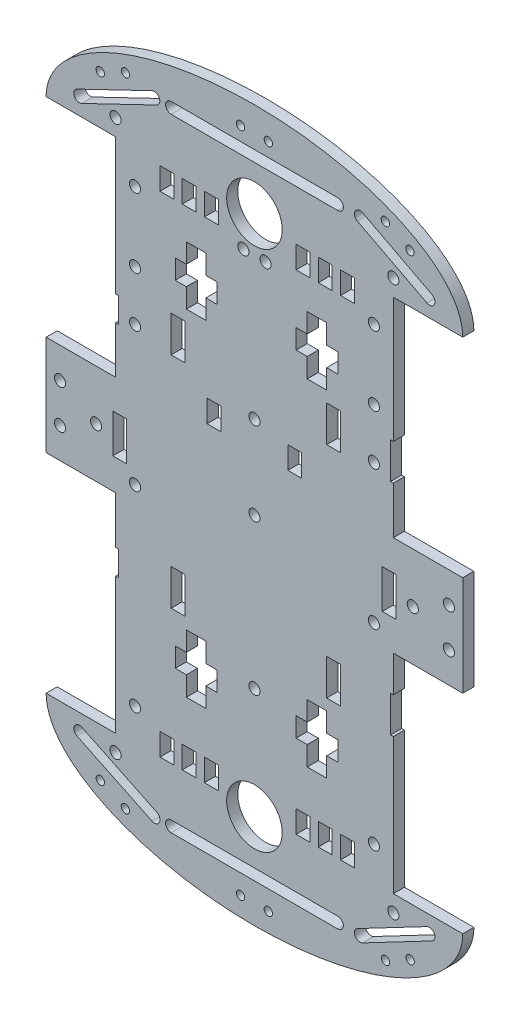
from build123d import *

# Parameters (mm, degrees)
SKETCH1_R           = 10
SKETCH1_R_2         = 1.972602619
BOSS_EXTRUDE2_DEPTH = 4
SKETCH3_R           = 2
CUT_EXTRUDE1_DEPTH  = 5.0000001
SKETCH4_R           = 2
CUT_EXTRUDE2_DEPTH  = 5.0000001
SKETCH5_W           = 5
SKETCH5_H           = 14
CUT_EXTRUDE3_DEPTH  = 5.0000001
SKETCH6_W           = 5
SKETCH6_H           = 14
CUT_EXTRUDE4_DEPTH  = 5.0000001
SKETCH7_W           = 5
SKETCH7_H           = 7.981312777
CUT_EXTRUDE6_DEPTH  = 5.0000001
SKETCH8_W           = 5
SKETCH8_H           = 8
CUT_EXTRUDE7_DEPTH  = 5.0000001
SKETCH9_W           = 5
SKETCH9_H           = 8
CUT_EXTRUDE8_DEPTH  = 5.0000001
SKETCH10_W          = 5
SKETCH10_H          = 8
CUT_EXTRUDE9_DEPTH  = 5.0000001
SKETCH11_W          = 5
SKETCH11_H          = 8
CUT_EXTRUDE10_DEPTH = 5.0000001
SKETCH12_W          = 5
SKETCH12_H          = 8
CUT_EXTRUDE12_DEPTH = 5.0000001
SKETCH13_W          = 5
SKETCH13_H          = 8
CUT_EXTRUDE13_DEPTH = 5.0000001
SKETCH14_W          = 5
SKETCH14_H          = 8
CUT_EXTRUDE14_DEPTH = 5.0000001
SKETCH15_W          = 5
SKETCH15_H          = 8
CUT_EXTRUDE15_DEPTH = 5.0000001
SKETCH16_W          = 5
SKETCH16_H          = 8
CUT_EXTRUDE16_DEPTH = 4
SKETCH17_W          = 5
SKETCH17_H          = 8
CUT_EXTRUDE17_DEPTH = 5.0000001
SKETCH18_W          = 5
SKETCH18_H          = 8
CUT_EXTRUDE18_DEPTH = 5.0000001
SKETCH19_R          = 2
CUT_EXTRUDE19_DEPTH = 5.0000001
SKETCH20_R          = 2
CUT_EXTRUDE20_DEPTH = 5.0000001
SKETCH21_R          = 2
CUT_EXTRUDE21_DEPTH = 5.0000001
SKETCH22_R          = 2
CUT_EXTRUDE22_DEPTH = 5.0000001
SKETCH23_R          = 2
CUT_EXTRUDE23_DEPTH = 5.0000001
SKETCH24_R          = 2
CUT_EXTRUDE24_DEPTH = 5.0000001
SKETCH25_W          = 5
SKETCH25_H          = 13
CUT_EXTRUDE25_DEPTH = 5.0000001
CUT_EXTRUDE26_DEPTH = 5.0000001
SKETCH27_W          = 5
SKETCH27_H          = 8
CUT_EXTRUDE27_DEPTH = 5.0000001
CUT_EXTRUDE29_DEPTH = 5.0000001
SKETCH29_R          = 1.5
CUT_EXTRUDE30_DEPTH = 5.0000001


with BuildPart() as part:
    # Sketch1 → Boss-Extrude2 (new body)
    with BuildSketch(Plane.XY):
        with BuildLine():
            Line((-50, 93), (-50, 44))
            Line((-50, 44), (-49, 44))
            Line((-49, 44), (-49, 35))
            Line((-49, 35), (-50, 35))
            Line((-50, 35), (-50, 18))
            Line((-50, 18), (-75, 18))
            Line((-75, 18), (-75, -18))
            Line((-75, -18), (-50, -18))
            Line((-50, -18), (-50, -35))
            Line((-50, -35), (-49, -35))
            Line((-49, -35), (-49, -44))
            Line((-49, -44), (-50, -44))
            Line((-50, -44), (-50, -93))
            Line((-50, -93), (-75, -93))
            add(Edge.make_bspline(
                [(-75, -93), (-75, -128), (0, -128), (75, -128), (75, -93)],
                knots=[3.141592654, 3.141592654, 3.141592654, 4.71238898, 4.71238898, 6.283185307, 6.283185307, 6.283185307], degree=2, weights=[1, 0.707106781, 1, 0.707106781, 1]))
            Line((75, -93), (50, -93))
            Line((50, -93), (50, -44))
            Line((50, -44), (49, -44))
            Line((49, -44), (49, -31))
            Line((49, -31), (50, -31))
            Line((50, -31), (50, -18))
            Line((50, -18), (75, -18))
            Line((75, -18), (75, 18))
            Line((75, 18), (50, 18))
            Line((50, 18), (50, 35))
            Line((50, 35), (49, 35))
            Line((49, 35), (49, 48))
            Line((49, 48), (50, 48))
            Line((50, 48), (50, 93))
            Line((50, 93), (75, 93))
            add(Edge.make_bspline(
                [(75, 93), (75, 128), (0, 128), (-75, 128), (-75, 93)],
                knots=[3.141592654, 3.141592654, 3.141592654, 4.71238898, 4.71238898, 6.283185307, 6.283185307, 6.283185307], degree=2, weights=[1, 0.707106781, 1, 0.707106781, 1]))
            Line((-75, 93), (-50, 93))
        make_face()
        with Locations((0, 94)):
            Circle(SKETCH1_R, mode=Mode.SUBTRACT)
        with Locations((0, -94)):
            Circle(SKETCH1_R, mode=Mode.SUBTRACT)
        Circle(SKETCH1_R_2, mode=Mode.SUBTRACT)
    extrude(amount=BOSS_EXTRUDE2_DEPTH)

    # Sketch3 → Cut-Extrude1 (cut, through all)
    with BuildSketch(Plane.XY.offset(4)):
        with Locations((0, 30)):
            Circle(SKETCH3_R)
    extrude(amount=-CUT_EXTRUDE1_DEPTH, mode=Mode.SUBTRACT)

    # Sketch4 → Cut-Extrude2 (cut, through all)
    with BuildSketch(Plane.XY.offset(4)):
        with Locations((0, -54)):
            Circle(SKETCH4_R)
    extrude(amount=-CUT_EXTRUDE2_DEPTH, mode=Mode.SUBTRACT)

    # Sketch5 → Cut-Extrude3 (cut, through all)
    with BuildSketch(Plane(origin=(0, 0, 0), x_dir=(-1, 0, 0), z_dir=(0, 0, -1))):
        with Locations((48.5, 0)):
            Rectangle(SKETCH5_W, SKETCH5_H)
    extrude(amount=-CUT_EXTRUDE3_DEPTH, mode=Mode.SUBTRACT)

    # Sketch6 → Cut-Extrude4 (cut, through all)
    with BuildSketch(Plane(origin=(0, 0, 0), x_dir=(-1, 0, 0), z_dir=(0, 0, -1))):
        with Locations((-48.5, 0)):
            Rectangle(SKETCH6_W, SKETCH6_H)
    extrude(amount=-CUT_EXTRUDE4_DEPTH, mode=Mode.SUBTRACT)

    # Sketch7 → Cut-Extrude6 (cut, through all)
    with BuildSketch(Plane(origin=(0, 0, 0), x_dir=(-1, 0, 0), z_dir=(0, 0, -1))):
        with Locations((-17.5, -87.990656388)):
            Rectangle(SKETCH7_W, SKETCH7_H)
    extrude(amount=-CUT_EXTRUDE6_DEPTH, mode=Mode.SUBTRACT)

    # Sketch8 → Cut-Extrude7 (cut, through all)
    with BuildSketch(Plane(origin=(0, 0, 0), x_dir=(-1, 0, 0), z_dir=(0, 0, -1))):
        with Locations((-25.5, -87.954976754)):
            Rectangle(SKETCH8_W, SKETCH8_H)
    extrude(amount=-CUT_EXTRUDE7_DEPTH, mode=Mode.SUBTRACT)

    # Sketch9 → Cut-Extrude8 (cut, through all)
    with BuildSketch(Plane(origin=(0, 0, 0), x_dir=(-1, 0, 0), z_dir=(0, 0, -1))):
        with Locations((-33.5, -87.954976754)):
            Rectangle(SKETCH9_W, SKETCH9_H)
    extrude(amount=-CUT_EXTRUDE8_DEPTH, mode=Mode.SUBTRACT)

    # Sketch10 → Cut-Extrude9 (cut, through all)
    with BuildSketch(Plane(origin=(0, 0, 0), x_dir=(-1, 0, 0), z_dir=(0, 0, -1))):
        with Locations((15.5, -88.404414437)):
            Rectangle(SKETCH10_W, SKETCH10_H)
    extrude(amount=-CUT_EXTRUDE9_DEPTH, mode=Mode.SUBTRACT)

    # Sketch11 → Cut-Extrude10 (cut, through all)
    with BuildSketch(Plane(origin=(0, 0, 0), x_dir=(-1, 0, 0), z_dir=(0, 0, -1))):
        with Locations((23.5, -88.404414437)):
            Rectangle(SKETCH11_W, SKETCH11_H)
    extrude(amount=-CUT_EXTRUDE10_DEPTH, mode=Mode.SUBTRACT)

    # Sketch12 → Cut-Extrude12 (cut, through all)
    with BuildSketch(Plane(origin=(0, 0, 0), x_dir=(-1, 0, 0), z_dir=(0, 0, -1))):
        with Locations((31.5, -88.404414437)):
            Rectangle(SKETCH12_W, SKETCH12_H)
    extrude(amount=-CUT_EXTRUDE12_DEPTH, mode=Mode.SUBTRACT)

    # Sketch13 → Cut-Extrude13 (cut, through all)
    with BuildSketch(Plane(origin=(0, 0, 0), x_dir=(-1, 0, 0), z_dir=(0, 0, -1))):
        with Locations((15.5, 88)):
            Rectangle(SKETCH13_W, SKETCH13_H)
    extrude(amount=-CUT_EXTRUDE13_DEPTH, mode=Mode.SUBTRACT)

    # Sketch14 → Cut-Extrude14 (cut, through all)
    with BuildSketch(Plane(origin=(0, 0, 0), x_dir=(-1, 0, 0), z_dir=(0, 0, -1))):
        with Locations((23.5, 88)):
            Rectangle(SKETCH14_W, SKETCH14_H)
    extrude(amount=-CUT_EXTRUDE14_DEPTH, mode=Mode.SUBTRACT)

    # Sketch15 → Cut-Extrude15 (cut, through all)
    with BuildSketch(Plane(origin=(0, 0, 0), x_dir=(-1, 0, 0), z_dir=(0, 0, -1))):
        with Locations((31.5, 88)):
            Rectangle(SKETCH15_W, SKETCH15_H)
    extrude(amount=-CUT_EXTRUDE15_DEPTH, mode=Mode.SUBTRACT)

    # Sketch16 → Cut-Extrude16 (cut)
    with BuildSketch(Plane(origin=(0, 0, 0), x_dir=(-1, 0, 0), z_dir=(0, 0, -1))):
        with Locations((-17.5, 88)):
            Rectangle(SKETCH16_W, SKETCH16_H)
    extrude(amount=-CUT_EXTRUDE16_DEPTH, mode=Mode.SUBTRACT)

    # Sketch17 → Cut-Extrude17 (cut, through all)
    with BuildSketch(Plane(origin=(0, 0, 0), x_dir=(-1, 0, 0), z_dir=(0, 0, -1))):
        with Locations((-25.5, 88)):
            Rectangle(SKETCH17_W, SKETCH17_H)
    extrude(amount=-CUT_EXTRUDE17_DEPTH, mode=Mode.SUBTRACT)

    # Sketch18 → Cut-Extrude18 (cut, through all)
    with BuildSketch(Plane(origin=(0, 0, 0), x_dir=(-1, 0, 0), z_dir=(0, 0, -1))):
        with Locations((-33.49998199, 87.989604923)):
            Rectangle(SKETCH18_W, SKETCH18_H)
    extrude(amount=-CUT_EXTRUDE18_DEPTH, mode=Mode.SUBTRACT)

    # Sketch19 → Cut-Extrude19 (cut, through all)
    with BuildSketch(Plane(origin=(0, 0, 0), x_dir=(-1, 0, 0), z_dir=(0, 0, -1))):
        with Locations((-57, 0)):
            Circle(SKETCH19_R)
        with Locations((-70, 7.0078078)):
            Circle(SKETCH19_R)
        with Locations((-70, -7)):
            Circle(SKETCH19_R)
    extrude(amount=-CUT_EXTRUDE19_DEPTH, mode=Mode.SUBTRACT)

    # Sketch20 → Cut-Extrude20 (cut, through all)
    with BuildSketch(Plane(origin=(0, 0, 0), x_dir=(-1, 0, 0), z_dir=(0, 0, -1))):
        with Locations((57, 0)):
            Circle(SKETCH20_R)
        with Locations((70, 7)):
            Circle(SKETCH20_R)
        with Locations((70, -7)):
            Circle(SKETCH20_R)
    extrude(amount=-CUT_EXTRUDE20_DEPTH, mode=Mode.SUBTRACT)

    # Sketch21 → Cut-Extrude21 (cut, through all)
    with BuildSketch(Plane(origin=(0, 0, 0), x_dir=(-1, 0, 0), z_dir=(0, 0, -1))):
        with Locations((4, 81)):
            Circle(SKETCH21_R)
        with Locations((-4, 81)):
            Circle(SKETCH21_R)
    extrude(amount=-CUT_EXTRUDE21_DEPTH, mode=Mode.SUBTRACT)

    # Sketch22 → Cut-Extrude22 (cut, through all)
    with BuildSketch(Plane(origin=(0, 0, 0), x_dir=(-1, 0, 0), z_dir=(0, 0, -1))):
        with Locations((43, 81)):
            Circle(SKETCH22_R)
        with Locations((-43, 81)):
            Circle(SKETCH22_R)
    extrude(amount=-CUT_EXTRUDE22_DEPTH, mode=Mode.SUBTRACT)

    # Sketch23 → Cut-Extrude23 (cut, through all)
    with BuildSketch(Plane.XY.offset(4)):
        with Locations((43, -81)):
            Circle(SKETCH23_R)
        with Locations((-43, -81)):
            Circle(SKETCH23_R)
    extrude(amount=-CUT_EXTRUDE23_DEPTH, mode=Mode.SUBTRACT)

    # Sketch24 → Cut-Extrude24 (cut, through all)
    with BuildSketch(Plane.XY.offset(4)):
        with Locations((-50, -99)):
            Circle(SKETCH24_R)
        with Locations((50, -99)):
            Circle(SKETCH24_R)
        with Locations((-50, 99)):
            Circle(SKETCH24_R)
        with Locations((50, 99)):
            Circle(SKETCH24_R)
        with Locations((43, -12)):
            Circle(SKETCH24_R)
        with Locations((43, 38)):
            Circle(SKETCH24_R)
        with Locations((-43, -12)):
            Circle(SKETCH24_R)
        with Locations((-43, 38)):
            Circle(SKETCH24_R)
        with Locations((43, 56)):
            Circle(SKETCH24_R)
        with Locations((-43, 56)):
            Circle(SKETCH24_R)
    extrude(amount=-CUT_EXTRUDE24_DEPTH, mode=Mode.SUBTRACT)

    # Sketch25 → Cut-Extrude25 (cut, through all)
    with BuildSketch(Plane(origin=(0, 0, 0), x_dir=(-1, 0, 0), z_dir=(0, 0, -1))):
        with Locations((-28.5, 41.5)):
            Rectangle(SKETCH25_W, SKETCH25_H)
        with Locations((27.5, 41.5)):
            Rectangle(SKETCH25_W, SKETCH25_H)
        with Locations((-28.5, -37.5)):
            Rectangle(SKETCH25_W, SKETCH25_H)
        with Locations((27.5, -37.5)):
            Rectangle(SKETCH25_W, SKETCH25_H)
    extrude(amount=-CUT_EXTRUDE25_DEPTH, mode=Mode.SUBTRACT)

    # Sketch26 → Cut-Extrude26 (cut, through all)
    with BuildSketch(Plane(origin=(0, 0, 0), x_dir=(-1, 0, 0), z_dir=(0, 0, -1))):
        Polygon((24.510151311, 52), (17.510151311, 52), (17.510151311, 59), (13.510151311, 59), (13.510151311, 66), (17.510151311, 66), (17.510151311, 73), (24.510151311, 73), (24.510151311, 66), (28.510151311, 66), (28.510151311, 59), (24.510151311, 59), align=None)
        Polygon((-30, 59), (-30, 66), (-26, 66), (-26, 73), (-19, 73), (-19, 66), (-15, 66), (-15, 59), (-19, 59), (-19, 52), (-26, 52), (-26, 59), align=None)
        Polygon((-19, -69), (-19, -62), (-15, -62), (-15, -55), (-19, -55), (-19, -48), (-26, -48), (-26, -55), (-30, -55), (-30, -62), (-26, -62), (-26, -69), align=None)
        Polygon((24.510151311, -48), (17.510151311, -48), (17.510151311, -55), (13.510151311, -55), (13.510151311, -62), (17.510151311, -62), (17.510151311, -69), (24.510151311, -69), (24.510151311, -62), (28.510151311, -62), (28.510151311, -55), (24.510151311, -55), align=None)
    extrude(amount=-CUT_EXTRUDE26_DEPTH, mode=Mode.SUBTRACT)

    # Sketch27 → Cut-Extrude27 (cut, through all)
    with BuildSketch(Plane(origin=(0, 0, 0), x_dir=(-1, 0, 0), z_dir=(0, 0, -1))):
        with Locations((-14.5, 24)):
            Rectangle(SKETCH27_W, SKETCH27_H)
        with Locations((14.52596989, 24)):
            Rectangle(SKETCH27_W, SKETCH27_H)
    extrude(amount=-CUT_EXTRUDE27_DEPTH, mode=Mode.SUBTRACT)

    # Sketch28 → Cut-Extrude29 (cut, through all)
    with BuildSketch(Plane(origin=(0, 0, 0), x_dir=(-1, 0, 0), z_dir=(0, 0, -1))):
        with BuildLine():
            Line((-30, 114), (30, 114))
            ThreePointArc((30, 114), (32, 112), (30, 110))
            Line((30, 110), (-30, 110))
            ThreePointArc((-30, 110), (-32, 112), (-30, 114))
        make_face()
        with BuildLine():
            Line((-30, -110), (30, -110))
            ThreePointArc((30, -110), (32, -112), (30, -114))
            Line((30, -114), (-30, -114))
            ThreePointArc((-30, -114), (-32, -112), (-30, -110))
        make_face()
        with BuildLine():
            Line((-63.92270495, 100.774433875), (-38.92268694, 113.774433875))
            ThreePointArc((-38.92268694, 113.774433875), (-36.225548116, 112.92270495), (-37.07727704, 110.225566125))
            Line((-37.07727704, 110.225566125), (-62.07729505, 97.225566125))
            ThreePointArc((-62.07729505, 97.225566125), (-64.774433875, 98.07729505), (-63.92270495, 100.774433875))
        make_face()
        with BuildLine():
            Line((36.930603123, 113.892071555), (63.915919056, 100.902834201))
            ThreePointArc((63.915919056, 100.902834201), (64.850587719, 98.233303439), (62.181056958, 97.298634775))
            Line((62.181056958, 97.298634775), (35.195741025, 110.287872129))
            ThreePointArc((35.195741025, 110.287872129), (34.261072361, 112.957402891), (36.930603123, 113.892071555))
        make_face()
        with BuildLine():
            Line((35.132368762, -110.19799666), (62.132368762, -97.19799666))
            ThreePointArc((62.132368762, -97.19799666), (64.80200334, -98.132368762), (63.867631238, -100.80200334))
            Line((63.867631238, -100.80200334), (36.867631238, -113.80200334))
            ThreePointArc((36.867631238, -113.80200334), (34.19799666, -112.867631238), (35.132368762, -110.19799666))
        make_face()
        with BuildLine():
            Line((-62.070563417, -97.229082826), (-37.070563417, -110.349919249))
            ThreePointArc((-37.070563417, -110.349919249), (-36.229082826, -113.050273006), (-38.929436583, -113.891753598))
            Line((-38.929436583, -113.891753598), (-63.929436583, -100.770917174))
            ThreePointArc((-63.929436583, -100.770917174), (-64.770917174, -98.070563417), (-62.070563417, -97.229082826))
        make_face()
    extrude(amount=-CUT_EXTRUDE29_DEPTH, mode=Mode.SUBTRACT)

    # Sketch29 → Cut-Extrude30 (cut, through all)
    with BuildSketch(Plane(origin=(0, 0, 0), x_dir=(-1, 0, 0), z_dir=(0, 0, -1))):
        with Locations((5, 119)):
            Circle(SKETCH29_R)
        with Locations((-5, 119)):
            Circle(SKETCH29_R)
        with Locations((55.506474964, 110.499757604)):
            Circle(SKETCH29_R)
        with Locations((46.448535029, 114.736941119)):
            Circle(SKETCH29_R)
        with Locations((-55.996466706, 110.53167505)):
            Circle(SKETCH29_R)
        with Locations((-47.124297333, 115.1451998)):
            Circle(SKETCH29_R)
        with Locations((5, -121)):
            Circle(SKETCH29_R)
        with Locations((-5, -121)):
            Circle(SKETCH29_R)
        with Locations((55.483257216, -110.388303448)):
            Circle(SKETCH29_R)
        with Locations((46.473240518, -114.726459636)):
            Circle(SKETCH29_R)
        with Locations((-47.205962341, -115.194747446)):
            Circle(SKETCH29_R)
        with Locations((-56.060548213, -110.547564533)):
            Circle(SKETCH29_R)
    extrude(amount=-CUT_EXTRUDE30_DEPTH, mode=Mode.SUBTRACT)


solid = part.part
